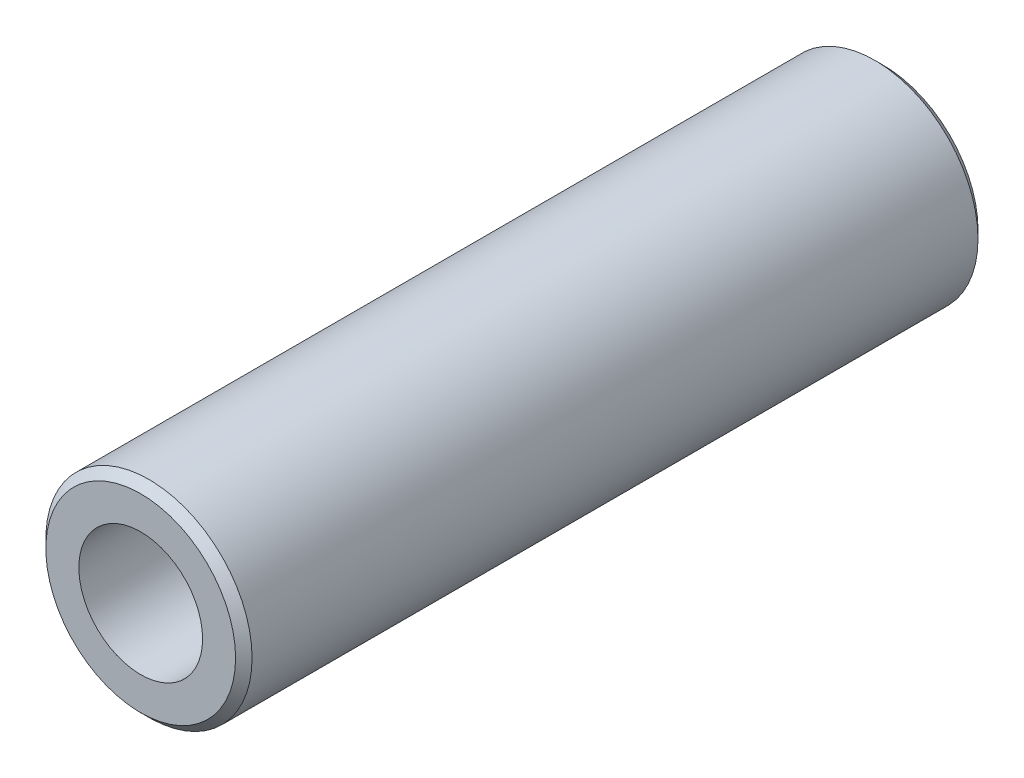
from build123d import *

# Parameters (mm, degrees)
SKETCH1_R           = 6.25
SKETCH1_R_2         = 3.75
EXTRUDE_THIN1_DEPTH = 22.5
CHAMFER1_SIZE       = 0.5


with BuildPart() as part:
    # Sketch1 → Extrude-Thin1 (new body, symmetric)
    with BuildSketch(Plane.XY):
        Circle(SKETCH1_R)
        Circle(SKETCH1_R_2, mode=Mode.SUBTRACT)
    extrude(amount=EXTRUDE_THIN1_DEPTH, both=True)

    # Chamfer1
    chamfer1_edges = [part.edges().sort_by_distance(p)[0] for p in [
        (-6.25, 0, -22.5),
        (-6.25, 0, 22.5),
    ]]
    chamfer(chamfer1_edges, length=CHAMFER1_SIZE)


solid = part.part
